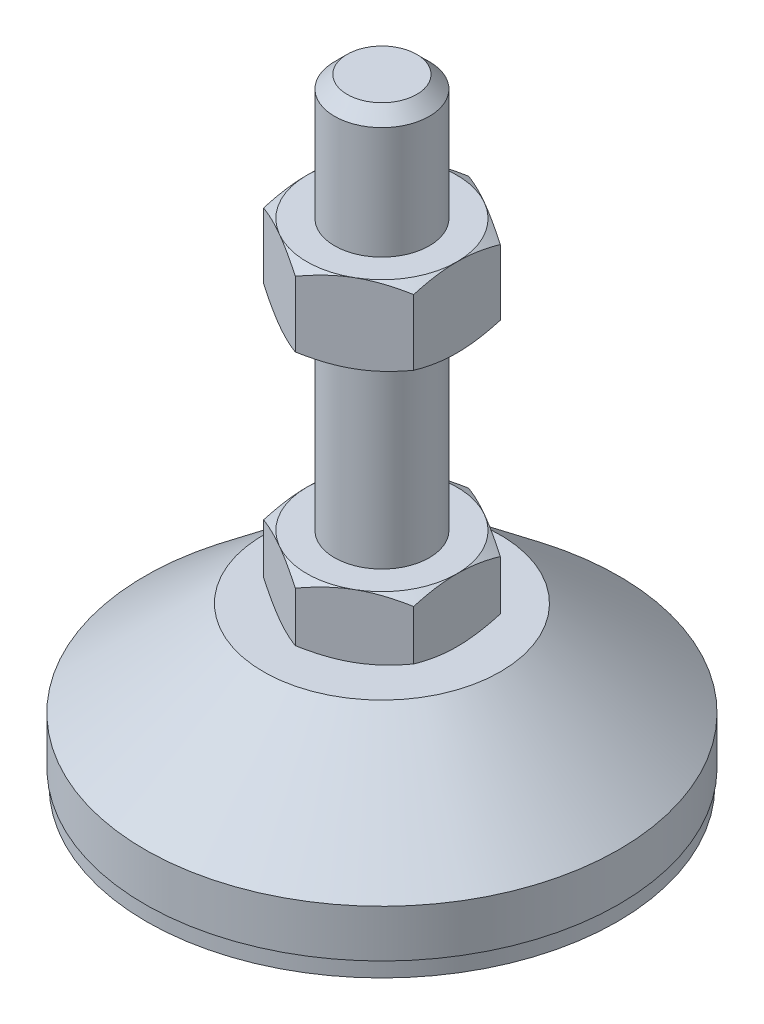
from build123d import *

# Parameters (mm, degrees)
EXTRUDE_1_DEPTH = 8
EXTRUDE_2_DEPTH = 10


with BuildPart() as part:
    # Эскиз1 → Повернуть1 (revolve)
    with BuildSketch(Plane.XY, mode=Mode.PRIVATE) as revolve_1_sk:
        Polygon((0, 0), (-29.8, 0), (-29.8, 2), (-30, 2), (-30, 8), (-15, 20), (-6, 20), (-6, 28), (-6, 76.4), (-4.4, 78), (0, 78), align=None)
    revolve(revolve_1_sk.sketch.rotate(Axis((0, 0, 0), (0, 1, 0)), 180), axis=Axis((0, 0, 0), (0, 1, 0)))  # turned: the seam where the file's is

    # Эскиз2 → Бобышка-Вытянуть1 (add)
    with BuildSketch(Plane(origin=(0, 20, 0), x_dir=(1, 0, 0), z_dir=(0, 1, 0))):
        Polygon((0, 10.969655115), (-9.5, 5.484827557), (-9.5, -5.484827557), (0, -10.969655115), (9.5, -5.484827557), (9.5, 5.484827557), align=None)
    extrude(amount=EXTRUDE_1_DEPTH)

    # Эскиз3 → Бобышка-Вытянуть2 (add)
    with BuildSketch(Plane(origin=(0, 52.2, 0), x_dir=(1, 0, 0), z_dir=(0, 1, 0))):
        Polygon((9.5, 5.484827557), (0, 10.969655115), (-9.5, 5.484827557), (-9.5, -5.484827557), (0, -10.969655115), (9.5, -5.484827557), align=None)
    extrude(amount=EXTRUDE_2_DEPTH)

    # Эскиз4 → Вырез-Повернуть2 (revolve, cut)
    with BuildSketch(Plane.XY, mode=Mode.PRIVATE) as cut_revolve_2_sk:
        Polygon((-18.160254038, 62.2), (-9.5, 62.2), (-18.160254038, 57.2), align=None)
        Polygon((-18.160254038, 52.2), (-18.160254038, 57.2), (-9.5, 52.2), align=None)
        Polygon((-16.42820323, 28), (-16.42820323, 24), (-9.5, 28), align=None)
        Polygon((-16.42820323, 24), (-16.42820323, 20), (-9.5, 20), align=None)
    revolve(cut_revolve_2_sk.sketch.rotate(Axis((0, 78, 0), (0, 1, 0)), 180), axis=Axis((0, 78, 0), (0, 1, 0)), mode=Mode.SUBTRACT)  # turned: the seam where the file's is


solid = part.part
